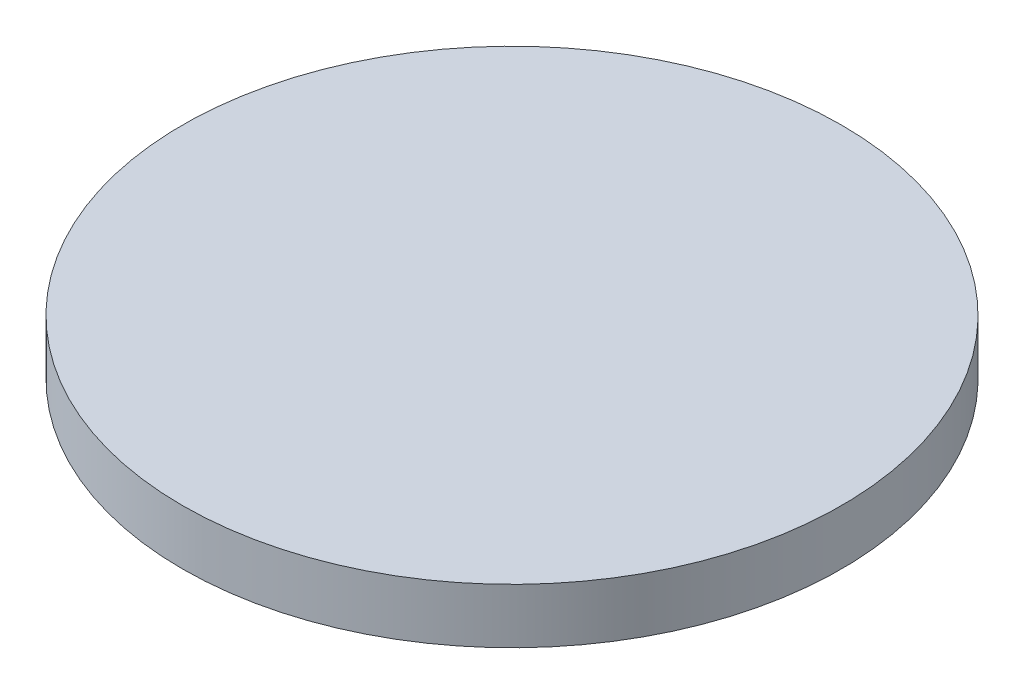
from build123d import *

# Parameters (mm, degrees)
ESQUISSE1_W = 12
ESQUISSE1_H = 2


with BuildPart() as part:
    # Esquisse1 → Révolution1 (revolve)
    with BuildSketch(Plane.XY, mode=Mode.PRIVATE) as r_volution1_sk:
        with Locations((6, 1)):
            Rectangle(ESQUISSE1_W, ESQUISSE1_H)
    revolve(r_volution1_sk.sketch.rotate(Axis((0, 5.140495868, 0), (0, -1, 0)), 90), axis=Axis((0, 5.140495868, 0), (0, -1, 0)))  # turned: the seam where the file's is


solid = part.part
